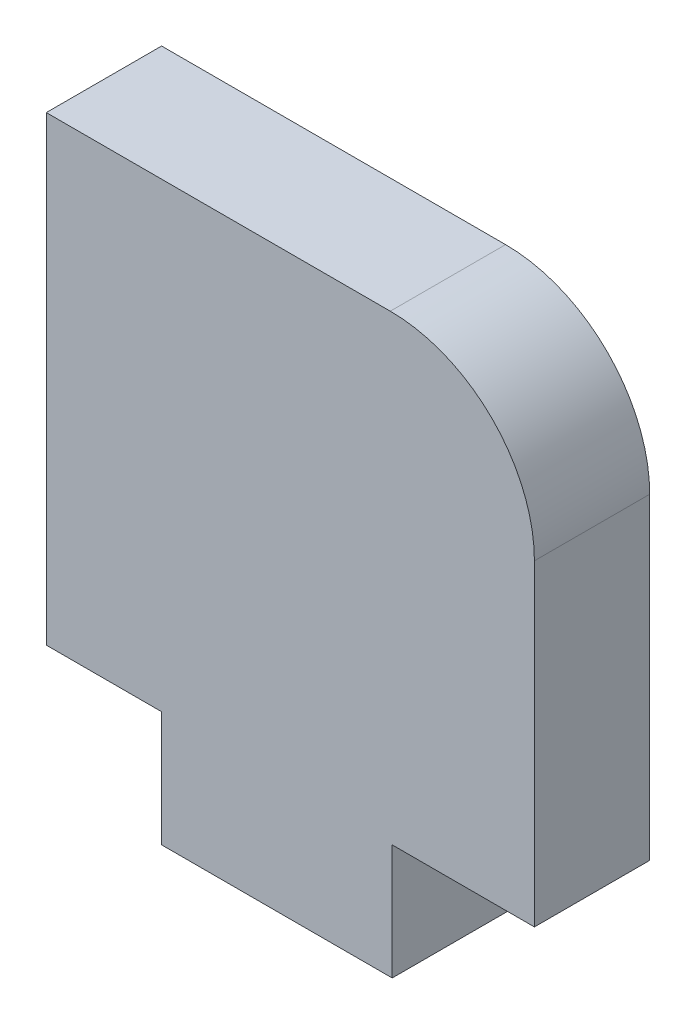
from build123d import *

# Parameters (mm, degrees)
BOSS_EXTRUDE1_DEPTH = 4


with BuildPart() as part:
    # Sketch1 → Boss-Extrude1 (new body)
    with BuildSketch(Plane.XY):
        with BuildLine():
            Line((6.07568334, -11), (11.008857545, -11))
            Line((11.008857545, -11), (11.008857545, 0))
            ThreePointArc((11.008857545, 0), (9.544391451, 3.535533906), (6.008857545, 5))
            Line((6.008857545, 5), (-5.92431666, 5))
            Line((-5.92431666, 5), (-5.92431666, -11))
            Line((-5.92431666, -11), (-1.92431666, -11))
            Line((-1.92431666, -11), (-1.92431666, -15))
            Line((-1.92431666, -15), (6.07568334, -15))
            Line((6.07568334, -15), (6.07568334, -11))
        make_face()
    extrude(amount=BOSS_EXTRUDE1_DEPTH)


solid = part.part
